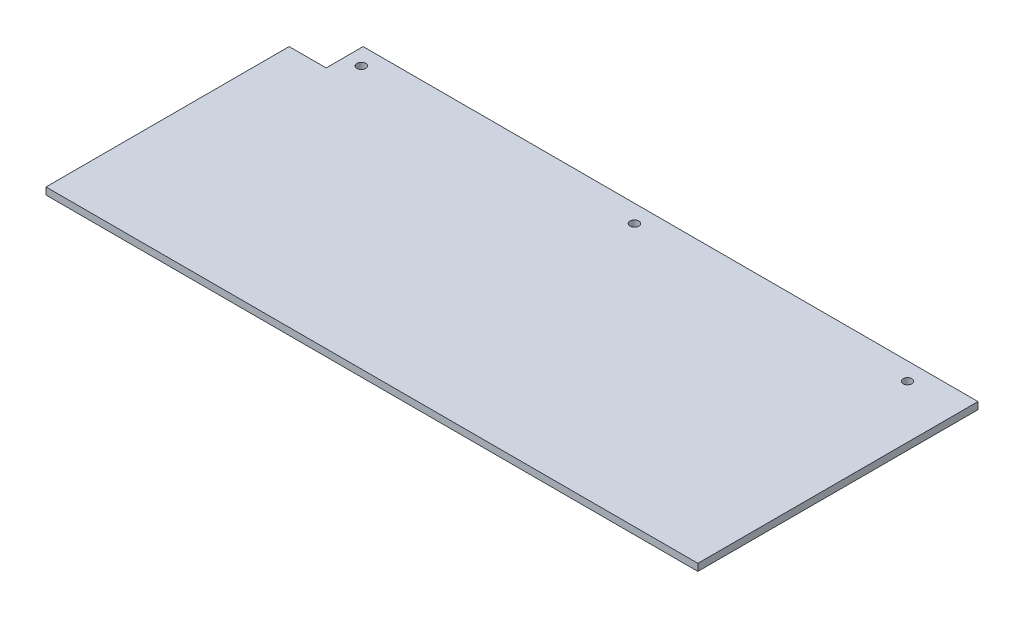
from build123d import *

# Parameters (mm, degrees)
SKETCH1_R           = 2.5
BOSS_EXTRUDE1_DEPTH = 4


with BuildPart() as part:
    # Sketch1 → Boss-Extrude1 (new body)
    with BuildSketch(Plane(origin=(0, 0, 0), x_dir=(1, 0, 0), z_dir=(0, 1, 0))):
        Polygon((-185, -69), (-185, 69), (-164, 69), (-164, 90), (185, 90), (185, -69), (-164, -69), align=None)
        with Locations((-155, 80)):
            Circle(SKETCH1_R, mode=Mode.SUBTRACT)
        with Locations((0, 80)):
            Circle(SKETCH1_R, mode=Mode.SUBTRACT)
        with Locations((155, 80)):
            Circle(SKETCH1_R, mode=Mode.SUBTRACT)
    extrude(amount=BOSS_EXTRUDE1_DEPTH)


solid = part.part
